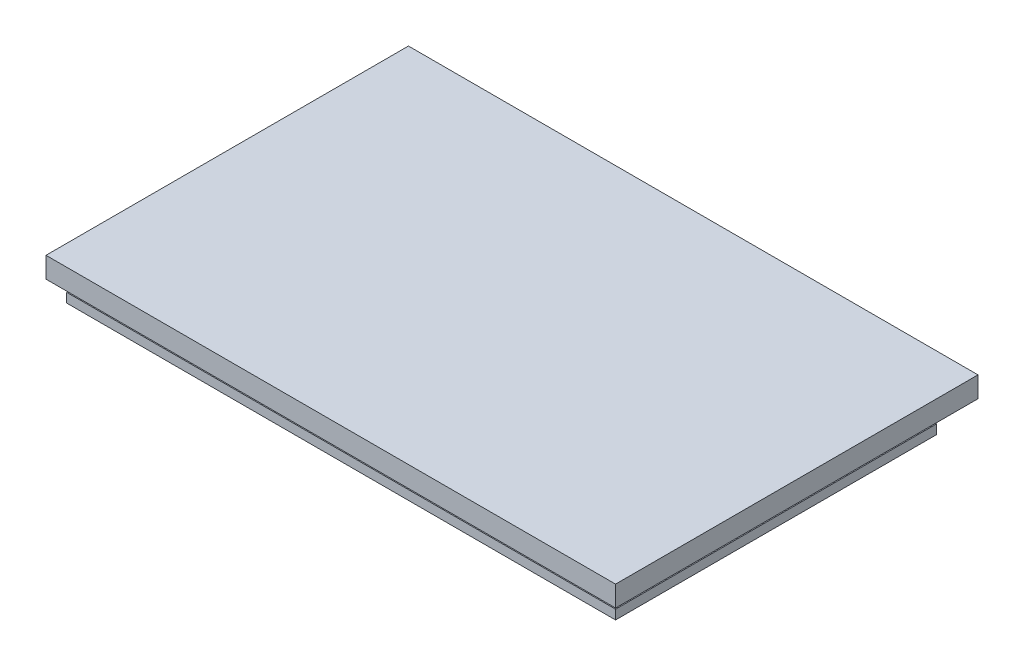
from build123d import *

# Parameters (mm, degrees)
SKETCH1_W           = 134.62
SKETCH1_H           = 78.74
BOSS_EXTRUDE1_DEPTH = 2.286
SKETCH2_W           = 129.54
SKETCH2_H           = 68.58
BOSS_EXTRUDE2_DEPTH = 5.334
SKETCH3_W           = 139.7
SKETCH3_H           = 88.9
BOSS_EXTRUDE3_DEPTH = 5.08


with BuildPart() as part:
    # Sketch1 → Boss-Extrude1 (new body)
    with BuildSketch(Plane(origin=(0, 0, 0), x_dir=(1, 0, 0), z_dir=(0, 1, 0))):
        with Locations((72.236796638, -12.067156206)):
            Rectangle(SKETCH1_W, SKETCH1_H)
    extrude(amount=BOSS_EXTRUDE1_DEPTH)

    # Sketch2 → Boss-Extrude2 (add)
    with BuildSketch(Plane(origin=(0, 2.286, 0), x_dir=(1, 0, 0), z_dir=(0, 1, 0))):
        with Locations((69.696796638, -12.067156206)):
            Rectangle(SKETCH2_W, SKETCH2_H)
    extrude(amount=BOSS_EXTRUDE2_DEPTH)

    # Sketch3 → Boss-Extrude3 (add)
    with BuildSketch(Plane(origin=(0, 7.62, 0), x_dir=(1, 0, 0), z_dir=(0, 1, 0))):
        with Locations((74.776796638, -12.067156206)):
            Rectangle(SKETCH3_W, SKETCH3_H)
    extrude(amount=BOSS_EXTRUDE3_DEPTH)


solid = part.part
